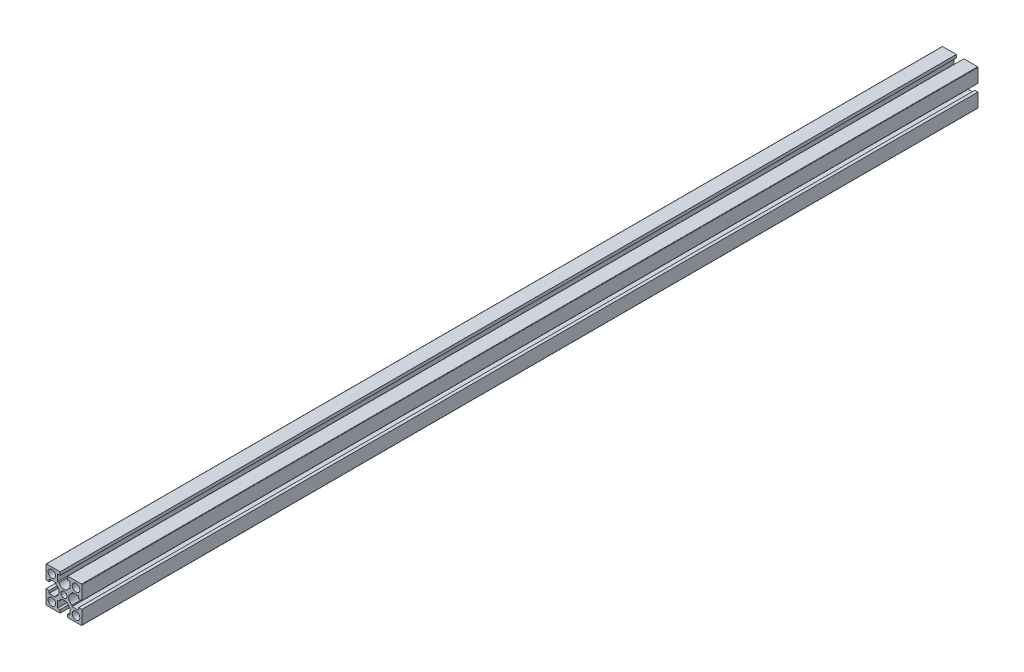
from build123d import *

# Parameters (mm, degrees)
SKETCH_1_R      = 4.25
SKETCH_1_R_2    = 3.4
EXTRUDE_1_DEPTH = 1000


with BuildPart() as part:
    # Эскиз1 → Бобышка-Вытянуть1 (new body)
    with BuildSketch(Plane.XY):
        with BuildLine():
            Line((-20, 19.5), (-20, 7))
            Line((-20, 7), (-20, 4.2))
            Line((-20, 4.2), (-16.5, 4.2))
            Line((-16.5, 4.2), (-16.5, 7))
            Line((-16.5, 7), (-9, 7))
            Line((-9, 7), (-9, 5.541660401))
            ThreePointArc((-9, 5.541660401), (-5.3, 0), (-9, -5.541660401))
            Line((-9, -5.541660401), (-9, -7))
            Line((-9, -7), (-16.5, -7))
            Line((-16.5, -7), (-16.5, -4.2))
            Line((-16.5, -4.2), (-20, -4.2))
            Line((-20, -4.2), (-20, -7))
            Line((-20, -7), (-20, -19.5))
            ThreePointArc((-20, -19.5), (-19.853553391, -19.853553391), (-19.5, -20))
            Line((-19.5, -20), (-7, -20))
            Line((-7, -20), (-4.2, -20))
            Line((-4.2, -20), (-4.2, -16.5))
            Line((-4.2, -16.5), (-7, -16.5))
            Line((-7, -16.5), (-7, -9))
            Line((-7, -9), (-5.541660401, -9))
            ThreePointArc((-5.541660401, -9), (0, -5.3), (5.541660401, -9))
            Line((5.541660401, -9), (7, -9))
            Line((7, -9), (7, -16.5))
            Line((7, -16.5), (4.2, -16.5))
            Line((4.2, -16.5), (4.2, -20))
            Line((4.2, -20), (7, -20))
            Line((7, -20), (19.5, -20))
            ThreePointArc((19.5, -20), (19.853553391, -19.853553391), (20, -19.5))
            Line((20, -19.5), (20, -7))
            Line((20, -7), (20, -4.2))
            Line((20, -4.2), (16.5, -4.2))
            Line((16.5, -4.2), (16.5, -7))
            Line((16.5, -7), (9, -7))
            Line((9, -7), (9, -5.541660401))
            ThreePointArc((9, -5.541660401), (5.3, 0), (9, 5.541660401))
            Line((9, 5.541660401), (9, 7))
            Line((9, 7), (16.5, 7))
            Line((16.5, 7), (16.5, 4.2))
            Line((16.5, 4.2), (20, 4.2))
            Line((20, 4.2), (20, 7))
            Line((20, 7), (20, 19.5))
            ThreePointArc((20, 19.5), (19.853553391, 19.853553391), (19.5, 20))
            Line((19.5, 20), (7, 20))
            Line((7, 20), (4.2, 20))
            Line((4.2, 20), (4.2, 16.5))
            Line((4.2, 16.5), (7, 16.5))
            Line((7, 16.5), (7, 9))
            Line((7, 9), (5.541660401, 9))
            ThreePointArc((5.541660401, 9), (0, 5.3), (-5.541660401, 9))
            Line((-5.541660401, 9), (-7, 9))
            Line((-7, 9), (-7, 16.5))
            Line((-7, 16.5), (-4.2, 16.5))
            Line((-4.2, 16.5), (-4.2, 20))
            Line((-4.2, 20), (-7, 20))
            Line((-7, 20), (-19.5, 20))
            ThreePointArc((-19.5, 20), (-19.853553391, 19.853553391), (-20, 19.5))
        make_face()
        with Locations((-13.5, -13.5)):
            Circle(SKETCH_1_R, mode=Mode.SUBTRACT)
        with Locations((13.5, -13.5)):
            Circle(SKETCH_1_R, mode=Mode.SUBTRACT)
        with Locations((-13.5, 13.5)):
            Circle(SKETCH_1_R, mode=Mode.SUBTRACT)
        Circle(SKETCH_1_R_2, mode=Mode.SUBTRACT)
        with Locations((13.5, 13.5)):
            Circle(SKETCH_1_R, mode=Mode.SUBTRACT)
    extrude(amount=EXTRUDE_1_DEPTH)


solid = part.part
